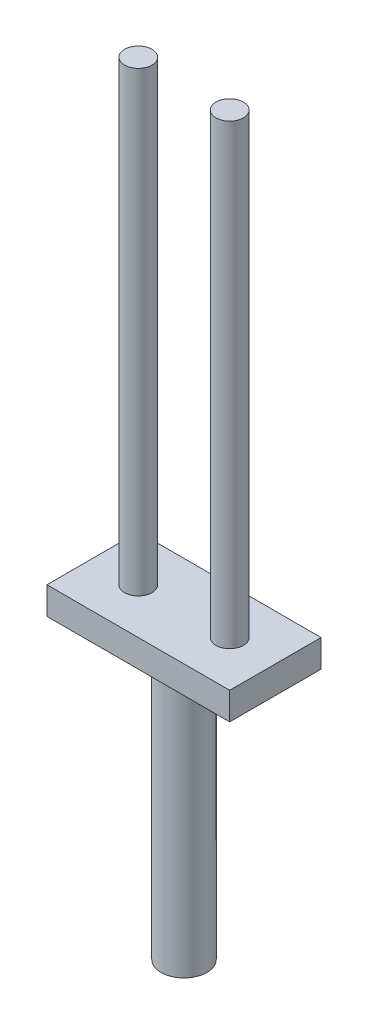
from build123d import *

# Parameters (mm, degrees)
SKETCH1_W           = 20
SKETCH1_H           = 10
BOSS_EXTRUDE1_DEPTH = 3
SKETCH2_R           = 1.5
BOSS_EXTRUDE2_DEPTH = 50
SKETCH3_R           = 2.5
BOSS_EXTRUDE3_DEPTH = 30


with BuildPart() as part:
    # Sketch1 → Boss-Extrude1 (new body)
    with BuildSketch(Plane(origin=(0, 0, 0), x_dir=(1, 0, 0), z_dir=(0, 1, 0))):
        Rectangle(SKETCH1_W, SKETCH1_H)
    extrude(amount=BOSS_EXTRUDE1_DEPTH)

    # Sketch2 → Boss-Extrude2 (add)
    with BuildSketch(Plane(origin=(0, 3, 0), x_dir=(1, 0, 0), z_dir=(0, 1, 0))):
        with Locations((-5, 0)):
            Circle(SKETCH2_R)
        with Locations((5, 0)):
            Circle(SKETCH2_R)
    extrude(amount=BOSS_EXTRUDE2_DEPTH)

    # Sketch3 → Boss-Extrude3 (add)
    with BuildSketch(Plane.XZ):
        Circle(SKETCH3_R)
    extrude(amount=BOSS_EXTRUDE3_DEPTH)


solid = part.part
